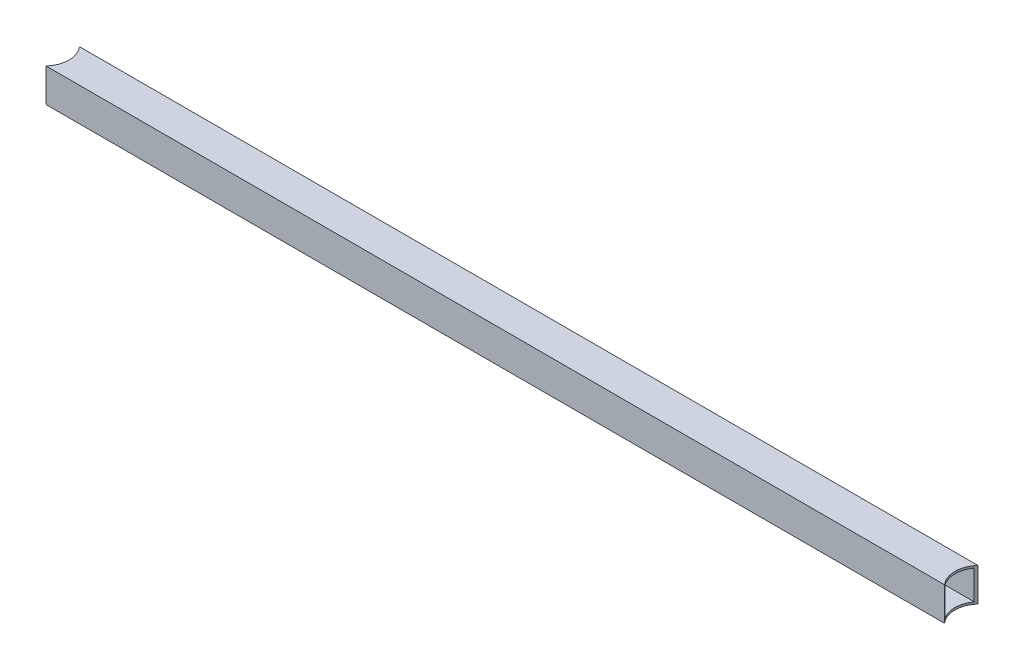
from build123d import *

# Parameters (mm, degrees)
SKETCH1_W           = 25.4
SKETCH1_H           = 25.4
SKETCH1_W_2         = 22.225
SKETCH1_H_2         = 22.225
BOSS_EXTRUDE1_DEPTH = 711.2
SKETCH2_R           = 19.05
CUT_EXTRUDE1_DEPTH  = 26.4


with BuildPart() as part:
    # Sketch1 → Boss-Extrude1 (new body)
    with BuildSketch(Plane(origin=(0, 0, 0), x_dir=(0, 0, -1), z_dir=(1, 0, 0))):
        with Locations((12.7, 12.7)):
            Rectangle(SKETCH1_W, SKETCH1_H)
        with Locations((12.7, 12.7)):
            Rectangle(SKETCH1_W_2, SKETCH1_H_2, mode=Mode.SUBTRACT)
    extrude(amount=BOSS_EXTRUDE1_DEPTH)

    # Sketch2 → Cut-Extrude1 (cut, through all)
    with BuildSketch(Plane(origin=(0, 25.4, 0), x_dir=(1, 0, 0), z_dir=(0, 1, 0))):
        with Locations((0, 12.7)):
            Circle(SKETCH2_R)
        with Locations((711.2, 12.7)):
            Circle(SKETCH2_R)
    extrude(amount=-CUT_EXTRUDE1_DEPTH, mode=Mode.SUBTRACT)


solid = part.part
